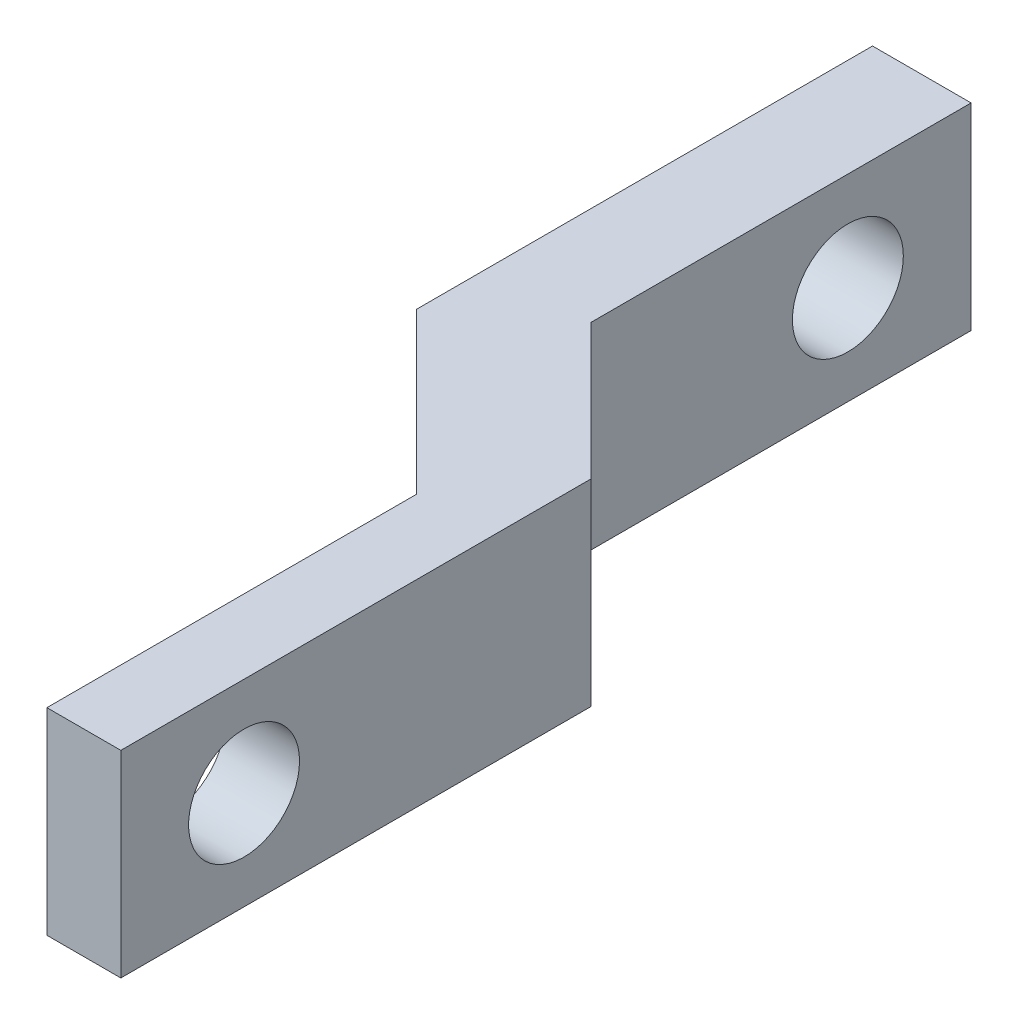
from build123d import *

# Parameters (mm, degrees)
BOSS_EXTRUDE1_DEPTH     = 8
SKETCH2_R               = 2.25
CUT_EXTRUDE1_DEPTH      = 6.5
CUT_EXTRUDE1_DEPTH_BACK = 5


with BuildPart() as part:
    # Sketch1 → Boss-Extrude1 (new body)
    with BuildSketch(Plane(origin=(0, 0, 0), x_dir=(1, 0, 0), z_dir=(0, 1, 0))):
        Polygon((0, 0), (-3, 0), (-3, 15), (-9.5, 21.5), (-9.5, 40), (-5.5, 40), (-5.5, 24.571067812), (0, 19.071067812), align=None)
    extrude(amount=BOSS_EXTRUDE1_DEPTH)

    # Sketch2 → Cut-Extrude1 (cut, two sides)
    with BuildSketch(Plane(origin=(-5.5, 0, 0), x_dir=(0, 0, -1), z_dir=(1, 0, 0))) as cut_extrude1_sk:
        with Locations((35, 4)):
            Circle(SKETCH2_R)
        with Locations((5, 4)):
            Circle(SKETCH2_R)
    extrude(amount=CUT_EXTRUDE1_DEPTH, mode=Mode.SUBTRACT)
    extrude(cut_extrude1_sk.sketch, amount=-CUT_EXTRUDE1_DEPTH_BACK, mode=Mode.SUBTRACT)


solid = part.part
